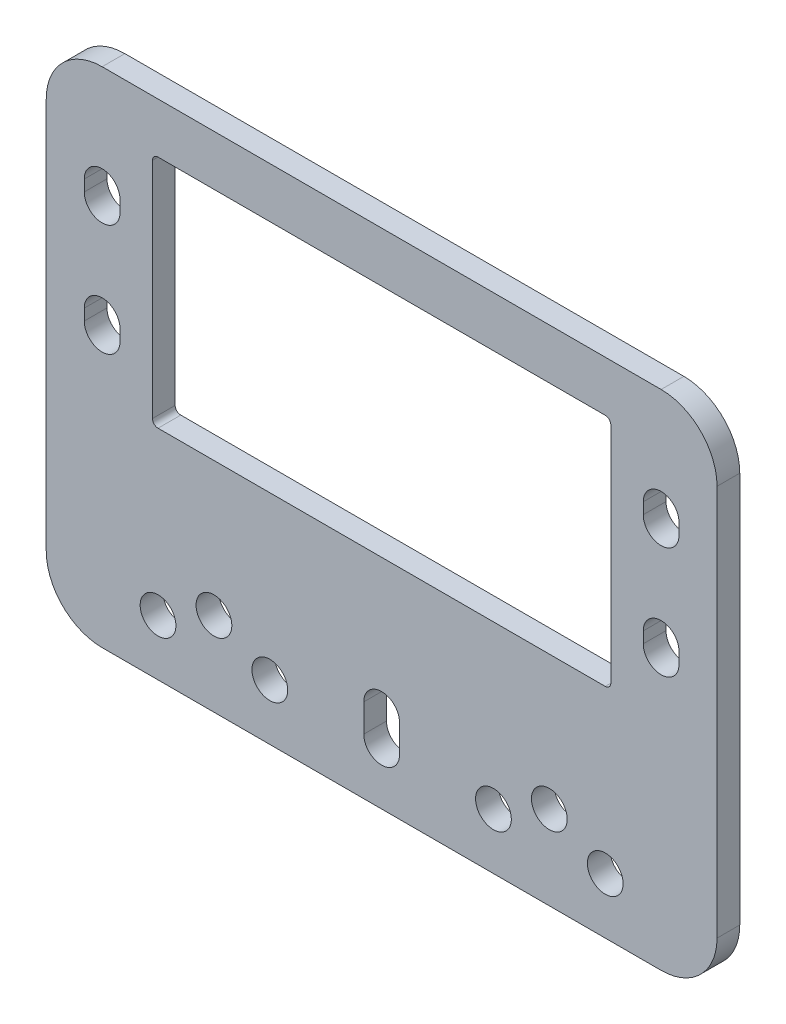
from build123d import *

# Parameters (mm, degrees)
SKETCH1_W           = 60
SKETCH1_H           = 45
BOSS_EXTRUDE1_DEPTH = 2.032
FILLET1_R           = 5
SKETCH2_W           = 41
SKETCH2_H           = 21
CUT_EXTRUDE1_DEPTH  = 3.032
FILLET2_R           = 0.5
CUT_EXTRUDE2_DEPTH  = 3.032
SKETCH4_R           = 1.6
CUT_EXTRUDE3_DEPTH  = 3.032


with BuildPart() as part:
    # Sketch1 → Boss-Extrude1 (new body)
    with BuildSketch(Plane.XY):
        Rectangle(SKETCH1_W, SKETCH1_H)
    extrude(amount=BOSS_EXTRUDE1_DEPTH)

    # Fillet1
    fillet1_edges = [part.edges().sort_by_distance(p)[0] for p in [
        (30, -22.5, 1.016),
        (-30, -22.5, 1.016),
        (-30, 22.5, 1.016),
        (30, 22.5, 1.016),
    ]]
    fillet(fillet1_edges, radius=FILLET1_R)

    # Sketch2 → Cut-Extrude1 (cut, through all)
    with BuildSketch(Plane.XY.offset(2.032)):
        with Locations((0, 7.5)):
            Rectangle(SKETCH2_W, SKETCH2_H)
    extrude(amount=-CUT_EXTRUDE1_DEPTH, mode=Mode.SUBTRACT)

    # Fillet2
    fillet2_edges = [part.edges().sort_by_distance(p)[0] for p in [
        (20.5, 18, 1.016),
        (20.5, -3, 1.016),
        (-20.5, -3, 1.016),
        (-20.5, 18, 1.016),
    ]]
    fillet(fillet2_edges, radius=FILLET2_R)

    # Sketch3 → Cut-Extrude2 (cut, through all)
    with BuildSketch(Plane.XY.offset(2.032)):
        with BuildLine():
            Line((-23.4, 3), (-23.4, 2))
            ThreePointArc((-23.4, 2), (-25, 0.4), (-26.6, 2))
            Line((-26.6, 2), (-26.6, 3))
            ThreePointArc((-26.6, 3), (-25, 4.6), (-23.4, 3))
        make_face()
        with BuildLine():
            Line((-23.4, 12), (-23.4, 13))
            ThreePointArc((-23.4, 13), (-25, 14.6), (-26.6, 13))
            Line((-26.6, 13), (-26.6, 12))
            ThreePointArc((-26.6, 12), (-25, 10.4), (-23.4, 12))
        make_face()
        with BuildLine():
            Line((23.4, 3), (23.4, 2))
            ThreePointArc((23.4, 2), (25, 0.4), (26.6, 2))
            Line((26.6, 2), (26.6, 3))
            ThreePointArc((26.6, 3), (25, 4.6), (23.4, 3))
        make_face()
        with BuildLine():
            Line((23.4, 12), (23.4, 13))
            ThreePointArc((23.4, 13), (25, 14.6), (26.6, 13))
            Line((26.6, 13), (26.6, 12))
            ThreePointArc((26.6, 12), (25, 10.4), (23.4, 12))
        make_face()
    extrude(amount=-CUT_EXTRUDE2_DEPTH, mode=Mode.SUBTRACT)

    # Sketch4 → Cut-Extrude3 (cut, through all)
    with BuildSketch(Plane.XY.offset(2.032)):
        with Locations((-15, -15)):
            Circle(SKETCH4_R)
        with Locations((15, -15)):
            Circle(SKETCH4_R)
        with Locations((10, -17.5)):
            Circle(SKETCH4_R)
        with Locations((-10, -17.5)):
            Circle(SKETCH4_R)
        with Locations((20, -17.5)):
            Circle(SKETCH4_R)
        with Locations((-20, -17.5)):
            Circle(SKETCH4_R)
        with BuildLine():
            Line((1.6, -15), (1.6, -17.5))
            ThreePointArc((1.6, -17.5), (0, -19.1), (-1.6, -17.5))
            Line((-1.6, -17.5), (-1.6, -15))
            ThreePointArc((-1.6, -15), (0, -13.4), (1.6, -15))
        make_face()
    extrude(amount=-CUT_EXTRUDE3_DEPTH, mode=Mode.SUBTRACT)


solid = part.part
